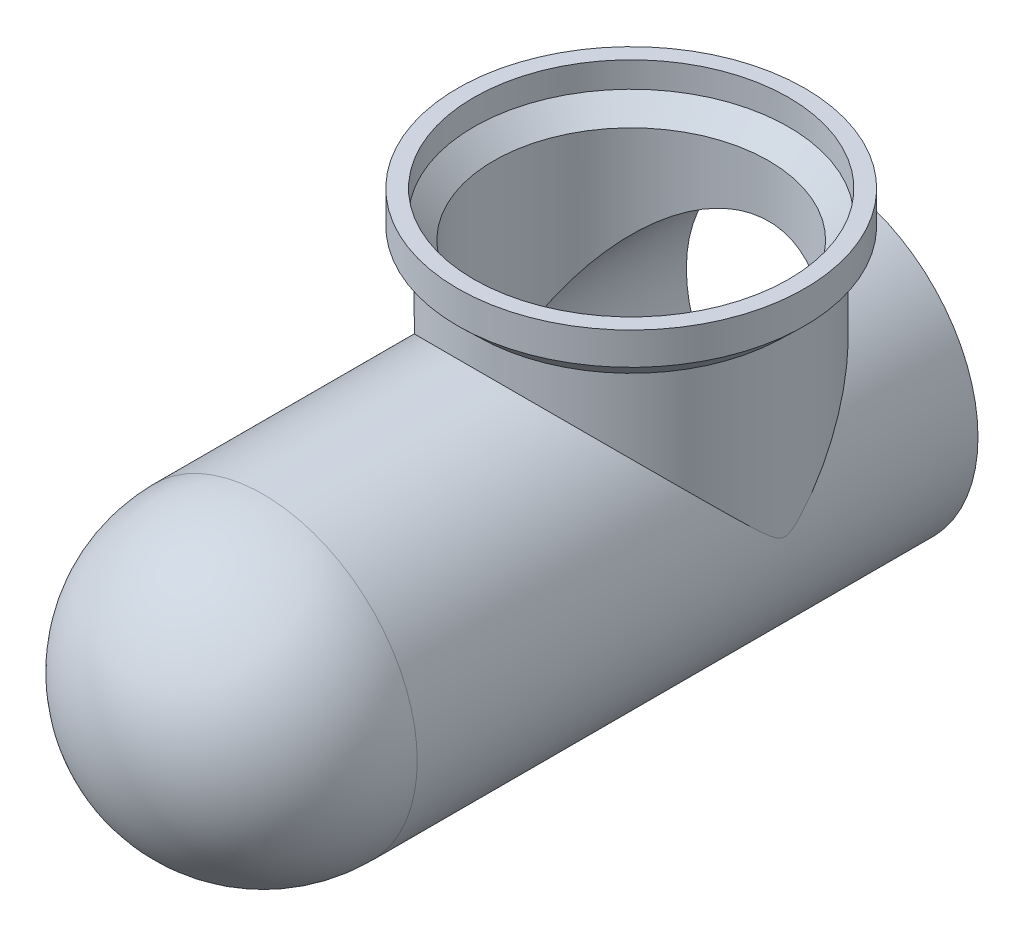
from build123d import *

# Parameters (mm, degrees)
SKETCH1_R           = 47.85
BOSS_EXTRUDE1_DEPTH = 222.25
SKETCH2_R           = 47.75
BOSS_EXTRUDE2_DEPTH = 57
FILLET1_R           = 47.85
SHELL1_T            = -5


with BuildPart() as part:
    # Sketch1 → Boss-Extrude1 (new body)
    with BuildSketch(Plane.XY):
        Circle(SKETCH1_R)
    extrude(amount=BOSS_EXTRUDE1_DEPTH)

    # Sketch2 → Boss-Extrude2 (add)
    with BuildSketch(Plane(origin=(0, 57, 0), x_dir=(1, 0, 0), z_dir=(0, 1, 0))):
        with Locations(Location((0, -60, 0), (0, 0, 270))):
            Circle(SKETCH2_R)
    extrude(amount=-BOSS_EXTRUDE2_DEPTH)

    # Sketch5 → Revolve3 (revolve)
    with BuildSketch(Plane(origin=(0, 0, 0), x_dir=(0, 0, -1), z_dir=(1, 0, 0)), mode=Mode.PRIVATE) as revolve3_sk:
        Polygon((-60, 57), (-12.25, 57), (-6.025, 63), (-6.025, 73.05), (-60, 73.05), align=None)
    revolve(revolve3_sk.sketch.rotate(Axis((0, 73.05, 60), (0, -1, 0)), 180), axis=Axis((0, 73.05, 60), (0, -1, 0)))

    # Fillet1
    fillet1_edges = [part.edges().sort_by_distance(p)[0] for p in [
        (-47.85, 0, 222.25),
    ]]
    fillet(fillet1_edges, radius=FILLET1_R)

    # Shell1
    shell1_openings = [part.faces().sort_by_distance(p)[0] for p in [
        (0, 73.05, 60),
        (0, 0, 0),
    ]]
    offset(amount=SHELL1_T, openings=shell1_openings, kind=Kind.INTERSECTION)


solid = part.part
